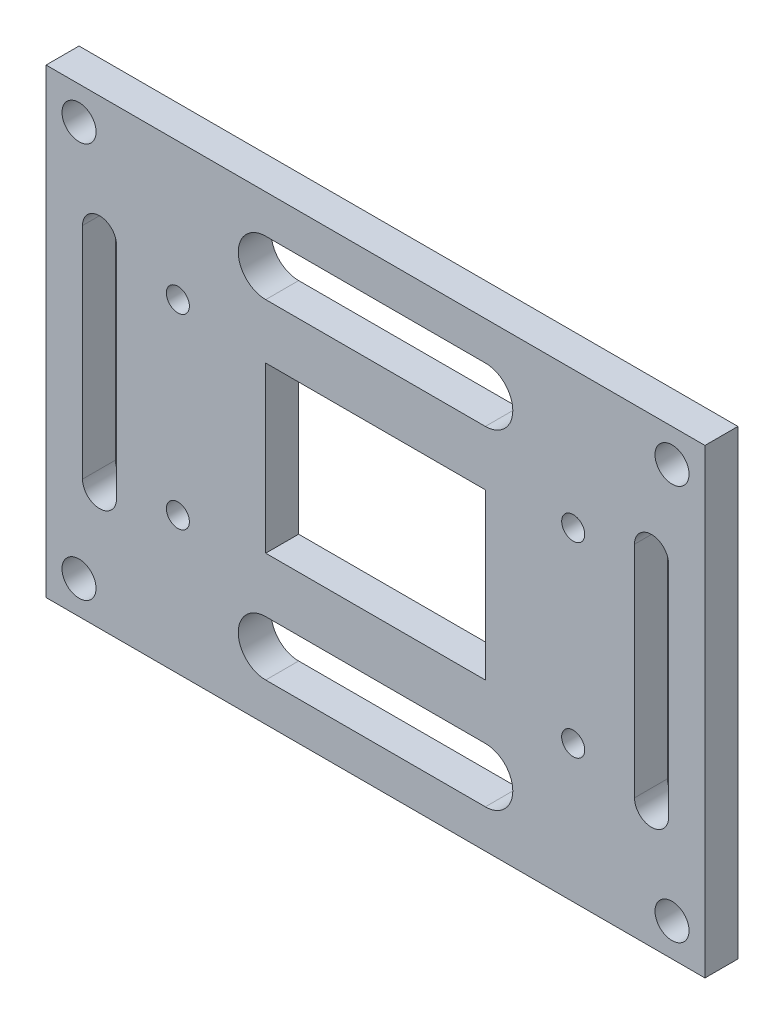
from build123d import *

# Parameters (mm, degrees)
SKETCH_1_W      = 60
SKETCH_1_H      = 42
SKETCH_1_R      = 1.05
SKETCH_1_R_2    = 1.55
SKETCH_1_W_2    = 20
SKETCH_1_H_2    = 15
EXTRUDE_1_DEPTH = 3


with BuildPart() as part:
    # 草图1 → 凸台-拉伸1 (new body)
    with BuildSketch(Plane.XY):
        Rectangle(SKETCH_1_W, SKETCH_1_H)
        with Locations((-18, -8.5)):
            Circle(SKETCH_1_R, mode=Mode.SUBTRACT)
        with Locations((-18, 8.5)):
            Circle(SKETCH_1_R, mode=Mode.SUBTRACT)
        with Locations((18, 8.5)):
            Circle(SKETCH_1_R, mode=Mode.SUBTRACT)
        with Locations((18, -8.5)):
            Circle(SKETCH_1_R, mode=Mode.SUBTRACT)
        with Locations((-27, -18)):
            Circle(SKETCH_1_R_2, mode=Mode.SUBTRACT)
        with Locations((27, -18)):
            Circle(SKETCH_1_R_2, mode=Mode.SUBTRACT)
        with Locations((27, 18)):
            Circle(SKETCH_1_R_2, mode=Mode.SUBTRACT)
        with Locations((-27, 18)):
            Circle(SKETCH_1_R_2, mode=Mode.SUBTRACT)
        Rectangle(SKETCH_1_W_2, SKETCH_1_H_2, mode=Mode.SUBTRACT)
        with BuildLine():
            Line((-10, 17.5), (10, 17.5))
            ThreePointArc((10, 17.5), (12.5, 15), (10, 12.5))
            Line((10, 12.5), (-10, 12.5))
            ThreePointArc((-10, 12.5), (-12.5, 15), (-10, 17.5))
        make_face(mode=Mode.SUBTRACT)
        with BuildLine():
            Line((-10, -17.5), (10, -17.5))
            ThreePointArc((10, -17.5), (12.5, -15), (10, -12.5))
            Line((10, -12.5), (-10, -12.5))
            ThreePointArc((-10, -12.5), (-12.5, -15), (-10, -17.5))
        make_face(mode=Mode.SUBTRACT)
        with BuildLine():
            Line((-23.583325542, 10), (-23.583325542, -10))
            ThreePointArc((-23.583325542, -10), (-25.133325542, -11.55), (-26.683325542, -10))
            Line((-26.683325542, -10), (-26.683325542, 10))
            ThreePointArc((-26.683325542, 10), (-25.133325542, 11.55), (-23.583325542, 10))
        make_face(mode=Mode.SUBTRACT)
        with BuildLine():
            Line((23.583325542, 10), (23.583325542, -10))
            ThreePointArc((23.583325542, -10), (25.133325542, -11.55), (26.683325542, -10))
            Line((26.683325542, -10), (26.683325542, 10))
            ThreePointArc((26.683325542, 10), (25.133325542, 11.55), (23.583325542, 10))
        make_face(mode=Mode.SUBTRACT)
    extrude(amount=EXTRUDE_1_DEPTH)


solid = part.part
